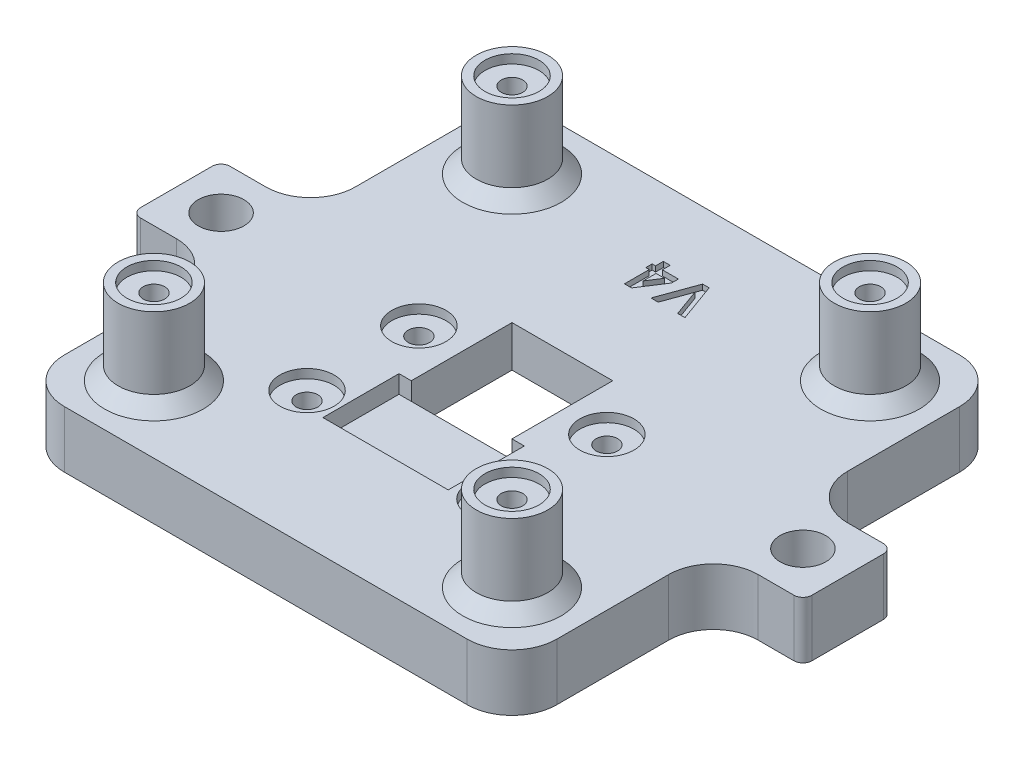
from build123d import *

# Parameters (mm, degrees)
SKETCH1_W                      = 55
SKETCH1_H                      = 55
BOSS_EXTRUDE1_DEPTH            = 6.35
SKETCH2_W                      = 11.25
SKETCH2_H                      = 11.25
CUT_EXTRUDE1_DEPTH             = 40.405868852
SKETCH3_W                      = 14
SKETCH3_H                      = 8.5
CUT_EXTRUDE2_DEPTH             = 2
CBORE_FOR_M2_SHCS2_D           = 2.4
CBORE_FOR_M2_SHCS2_CBORE_D     = 4.4
CBORE_FOR_M2_SHCS2_CBORE_DEPTH = 2
SKETCH6_R                      = 4
BOSS_EXTRUDE2_DEPTH            = 9.5
CBORE_FOR_M2_SHCS1_D           = 2.4
CBORE_FOR_M2_SHCS1_CBORE_D     = 4.4
CBORE_FOR_M2_SHCS1_CBORE_DEPTH = 2
SKETCH13_R                     = 3.025
CUT_EXTRUDE4_DEPTH             = 1
CHAMFER1_SIZE                  = 1.75
SKETCH16_W                     = 10
SKETCH16_H                     = 10
BOSS_EXTRUDE3_DEPTH            = 6.35
SKETCH17_R                     = 2.55
CUT_EXTRUDE6_DEPTH             = 50.129649907
FILLET1_R                      = 5
FILLET2_R                      = 1
SKETCH18_R                     = 3.025
CUT_EXTRUDE7_DEPTH             = 1
CUT_EXTRUDE8_DEPTH             = 0.6
CHAMFER2_SIZE                  = 1.5


with BuildPart() as part:
    # Sketch1 → Boss-Extrude1 (new body)
    with BuildSketch(Plane(origin=(0, 0, 0), x_dir=(1, 0, 0), z_dir=(0, 1, 0))):
        Rectangle(SKETCH1_W, SKETCH1_H)
    extrude(amount=BOSS_EXTRUDE1_DEPTH)

    # Sketch2 → Cut-Extrude1 (cut, through all)
    with BuildSketch(Plane(origin=(0, 6.35, 0), x_dir=(1, 0, 0), z_dir=(0, 1, 0))):
        Rectangle(SKETCH2_W, SKETCH2_H)
    extrude(amount=-CUT_EXTRUDE1_DEPTH, mode=Mode.SUBTRACT)

    # Sketch3 → Cut-Extrude2 (cut)
    with BuildSketch(Plane(origin=(0, 6.35, 0), x_dir=(1, 0, 0), z_dir=(0, 1, 0))):
        with Locations((0, -9.875)):
            Rectangle(SKETCH3_W, SKETCH3_H)
    extrude(amount=-CUT_EXTRUDE2_DEPTH, mode=Mode.SUBTRACT)

    # CBORE for M2 SHCS2 (through all)
    with Locations(Plane.XZ):
        with Locations((10.5, -0.1), (10.5, 12.4), (-10.5, 12.4), (-10.5, -0.1)):
            CounterBoreHole(CBORE_FOR_M2_SHCS2_D / 2, CBORE_FOR_M2_SHCS2_CBORE_D / 2, CBORE_FOR_M2_SHCS2_CBORE_DEPTH)

    # Sketch6 → Boss-Extrude2 (add)
    with BuildSketch(Plane(origin=(0, 6.35, 0), x_dir=(1, 0, 0), z_dir=(0, 1, 0))):
        with Locations(Location((-20, 20, 0), (0, 0, 270))):
            Circle(SKETCH6_R)
        with Locations(Location((20, 20, 0), (0, 0, 270))):
            Circle(SKETCH6_R)
        with Locations(Location((20, -20, 0), (0, 0, 270))):
            Circle(SKETCH6_R)
        with Locations(Location((-20, -20, 0), (0, 0, 270))):
            Circle(SKETCH6_R)
    extrude(amount=BOSS_EXTRUDE2_DEPTH)

    # CBORE for M2 SHCS1 (through all)
    with Locations(Plane.XZ):
        with Locations((-20, -20), (-20, 20), (20, 20), (20, -20)):
            CounterBoreHole(CBORE_FOR_M2_SHCS1_D / 2, CBORE_FOR_M2_SHCS1_CBORE_D / 2, CBORE_FOR_M2_SHCS1_CBORE_DEPTH)

    # Sketch13 → Cut-Extrude4 (cut)
    with BuildSketch(Plane(origin=(0, 6.35, 0), x_dir=(1, 0, 0), z_dir=(0, 1, 0))):
        with Locations(Location((-10.5, -12.4, 0), (0, 0, 270))):
            Circle(SKETCH13_R)
        with Locations(Location((-10.5, 0.1, 0), (0, 0, 270))):
            Circle(SKETCH13_R)
        with Locations(Location((10.5, -12.4, 0), (0, 0, 90))):
            Circle(SKETCH13_R)
        with Locations(Location((10.5, 0.1, 0), (0, 0, 90))):
            Circle(SKETCH13_R)
    extrude(amount=-CUT_EXTRUDE4_DEPTH, mode=Mode.SUBTRACT)

    # Chamfer1
    chamfer1_edges = [part.edges().sort_by_distance(p)[0] for p in [
        (5.625, 0, 0),
        (0, 0, 5.625),
        (-5.625, 0, 0),
        (0, 0, -5.625),
    ]]
    chamfer(chamfer1_edges, length=CHAMFER1_SIZE)

    # Sketch16 → Boss-Extrude3 (add)
    with BuildSketch(Plane.XZ):
        with Locations((32.5, 0)):
            Rectangle(SKETCH16_W, SKETCH16_H)
        with Locations((-32.5, 0)):
            Rectangle(SKETCH16_W, SKETCH16_H)
    extrude(amount=-BOSS_EXTRUDE3_DEPTH)

    # Sketch17 → Cut-Extrude6 (cut, through all)
    with BuildSketch(Plane.XZ):
        with Locations(Location((32.5, 0, 0), (0, 0, 270))):
            Circle(SKETCH17_R)
        with Locations(Location((-32.5, 0, 0), (0, 0, 270))):
            Circle(SKETCH17_R)
    extrude(amount=-CUT_EXTRUDE6_DEPTH, mode=Mode.SUBTRACT)

    # Fillet1
    fillet1_edges = [part.edges().sort_by_distance(p)[0] for p in [
        (27.5, 3.175, 5),
        (27.5, 3.175, -5),
        (-27.5, 3.175, -5),
        (-27.5, 3.175, 5),
        (27.5, 3.175, 27.5),
        (-27.5, 3.175, 27.5),
        (-27.5, 3.175, -27.5),
        (27.5, 3.175, -27.5),
    ]]
    fillet(fillet1_edges, radius=FILLET1_R)

    # Fillet2
    fillet2_edges = [part.edges().sort_by_distance(p)[0] for p in [
        (37.5, 3.175, -5),
        (37.5, 3.175, 5),
        (-37.5, 3.175, 5),
        (-37.5, 3.175, -5),
    ]]
    fillet(fillet2_edges, radius=FILLET2_R)

    # Sketch18 → Cut-Extrude7 (cut)
    with BuildSketch(Plane(origin=(0, 15.85, 0), x_dir=(1, 0, 0), z_dir=(0, 1, 0))):
        with Locations(Location((-20, 20, 0), (0, 0, 270))):
            Circle(SKETCH18_R)
        with Locations(Location((-20, -20, 0), (0, 0, 270))):
            Circle(SKETCH18_R)
        with Locations(Location((20, 20, 0), (0, 0, 270))):
            Circle(SKETCH18_R)
        with Locations(Location((20, -20, 0), (0, 0, 270))):
            Circle(SKETCH18_R)
    extrude(amount=-CUT_EXTRUDE7_DEPTH, mode=Mode.SUBTRACT)

    # Sketch19 → Cut-Extrude8 (cut)
    with BuildSketch(Plane(origin=(0, 6.35, 0), x_dir=(1, 0, 0), z_dir=(0, 1, 0))):
        Polygon((-2.301535791, 15.658119658), (-3.093589744, 15.658119658), (-3.093589744, 18.426068376), (-3.473504274, 18.426068376), (-3.473504274, 19.131623932), (-3.093589744, 19.131623932), (-3.093589744, 20), (-2.333760684, 20), (-2.333760684, 19.131623932), (-0.542735043, 19.131623932), (-0.542735043, 18.362466613), align=None)
        Polygon((-2.333760684, 18.426068376), (-2.333760684, 16.985276442), (-1.396694712, 18.426068376), align=None, mode=Mode.SUBTRACT)
        Polygon((3.55491453, 15.766666667), (2.743356036, 15.766666667), (1.65534188, 18.773758013), (0.564783654, 15.766666667), (-0.244230769, 15.766666667), (1.290691774, 20), (2.022536058, 20), align=None)
    extrude(amount=-CUT_EXTRUDE8_DEPTH, mode=Mode.SUBTRACT)

    # Chamfer2
    chamfer2_edges = [part.edges().sort_by_distance(p)[0] for p in [
        (-20, 6.35, -24),
        (20, 6.35, -24),
        (20, 6.35, 16),
        (-20, 6.35, 16),
    ]]
    chamfer(chamfer2_edges, length=CHAMFER2_SIZE)


solid = part.part
